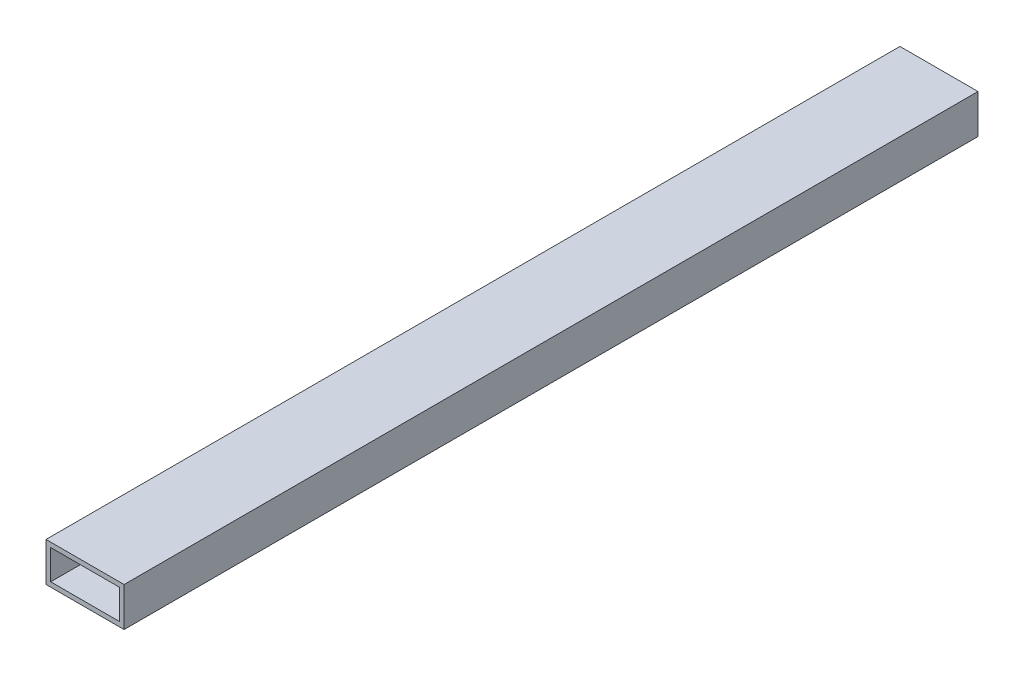
from build123d import *

# Parameters (mm, degrees)
BOSS_EXTRUDE1_START = 3.175
SKETCH1_W           = 50.8
SKETCH1_H           = 25.4
SKETCH1_W_2         = 44.704
SKETCH1_H_2         = 19.304
BOSS_EXTRUDE1_DEPTH = 555.625


with BuildPart() as part:
    # Sketch1 → Boss-Extrude1 (new body)
    with BuildSketch(Plane.XY.offset(BOSS_EXTRUDE1_START)):
        with Locations((25.4, 12.7)):
            Rectangle(SKETCH1_W, SKETCH1_H)
        with Locations((25.4, 12.7)):
            Rectangle(SKETCH1_W_2, SKETCH1_H_2, mode=Mode.SUBTRACT)
    extrude(amount=BOSS_EXTRUDE1_DEPTH)


solid = part.part
